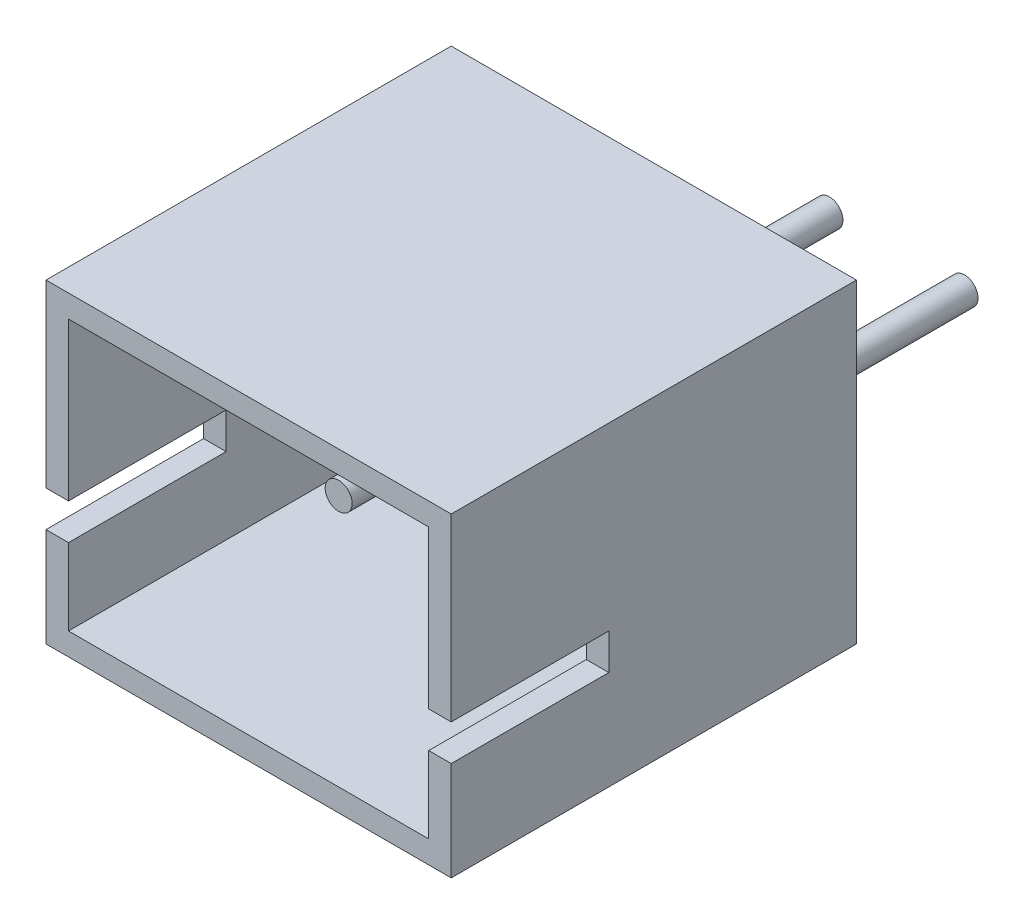
from build123d import *

# Parameters (mm, degrees)
SKETCH1_W                = 4.5
SKETCH1_H                = 3.5
BOSS_EXTRUDE1_DEPTH      = 4.5
SKETCH2_W                = 4
SKETCH2_H                = 3
CUT_EXTRUDE1_DEPTH       = 4.25
SKETCH3_R                = 0.15
BOSS_EXTRUDE2_DEPTH      = 2.7
BOSS_EXTRUDE2_DEPTH_BACK = 4
SKETCH4_W                = 3.5
SKETCH4_H                = 0.4
CUT_EXTRUDE2_DEPTH       = 5.5


with BuildPart() as part:
    # Sketch1 → Boss-Extrude1 (new body)
    with BuildSketch(Plane.XY):
        Rectangle(SKETCH1_W, SKETCH1_H)
    extrude(amount=BOSS_EXTRUDE1_DEPTH)

    # Sketch2 → Cut-Extrude1 (cut)
    with BuildSketch(Plane.XY.offset(4.5)):
        Rectangle(SKETCH2_W, SKETCH2_H)
    extrude(amount=-CUT_EXTRUDE1_DEPTH, mode=Mode.SUBTRACT)

    # Sketch3 → Boss-Extrude2 (add, two sides)
    with BuildSketch(Plane(origin=(0, 0, 0), x_dir=(-1, 0, 0), z_dir=(0, 0, -1))) as boss_extrude2_sk:
        with Locations((-0.75, -0.45)):
            Circle(SKETCH3_R)
        with Locations((0.75, -0.45)):
            Circle(SKETCH3_R)
    extrude(amount=BOSS_EXTRUDE2_DEPTH)
    extrude(boss_extrude2_sk.sketch, amount=-BOSS_EXTRUDE2_DEPTH_BACK)

    # Sketch4 → Cut-Extrude2 (cut, through all)
    with BuildSketch(Plane.ZY.offset(2.25)):
        with Locations((4.5, -0.45)):
            Rectangle(SKETCH4_W, SKETCH4_H)
    extrude(amount=-CUT_EXTRUDE2_DEPTH, mode=Mode.SUBTRACT)


solid = part.part
